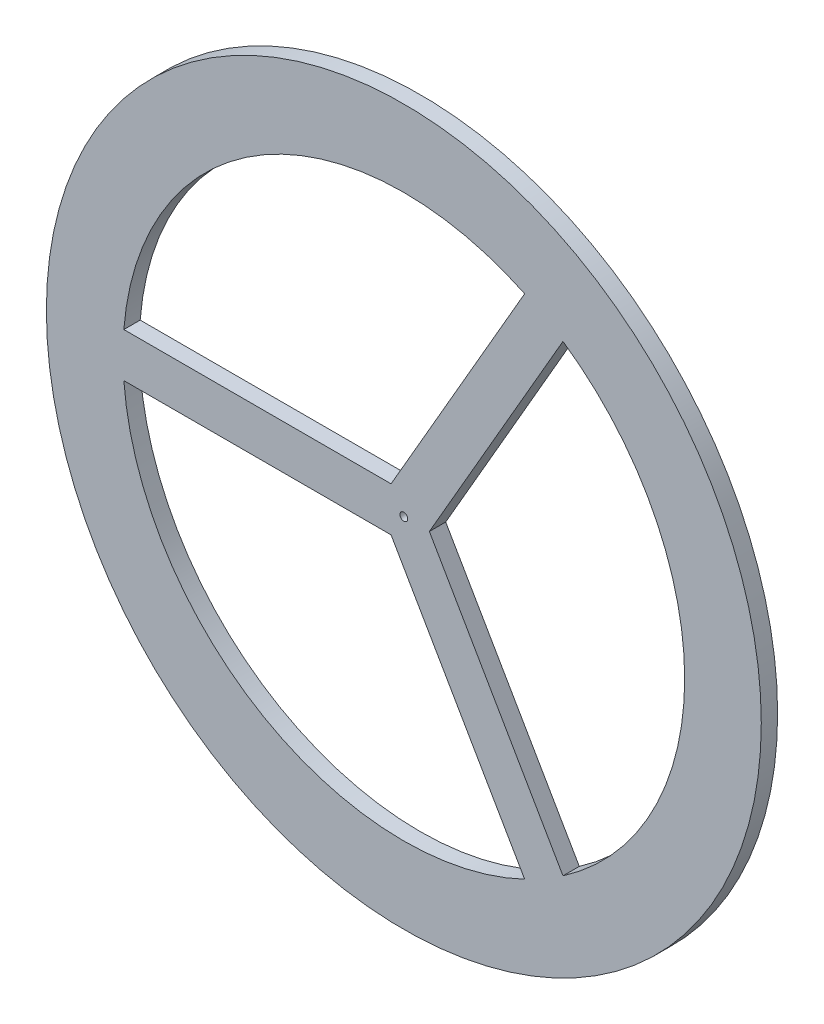
from build123d import *

# Parameters (mm, degrees)
SKETCH1_R               = 175
BOSS_EXTRUDE1_DEPTH     = 8
SKETCH2_R               = 1.9
CUT_EXTRUDE2_DEPTH      = 9
CUT_EXTRUDE2_DEPTH_BACK = 1


with BuildPart() as part:
    # Sketch1 → Boss-Extrude1 (new body)
    with BuildSketch(Plane.XY):
        Circle(SKETCH1_R)
        with BuildLine():
            Line((-6.25, 10.825317547), (-137.073201247, 10.825317547))
            ThreePointArc((-137.073201247, 10.825317547), (-68.75, 119.07849302), (59.161600623, 124.121533231))
            Line((59.161600623, 124.121533231), (-6.25, 10.825317547))
        make_face(mode=Mode.SUBTRACT)
        with BuildLine():
            Line((-6.25, -10.825317547), (-137.073201247, -10.825317547))
            ThreePointArc((-137.073201247, -10.825317547), (-68.75, -119.07849302), (59.161600623, -124.121533231))
            Line((59.161600623, -124.121533231), (-6.25, -10.825317547))
        make_face(mode=Mode.SUBTRACT)
        with BuildLine():
            Line((12.5, 0), (77.911600623, 113.296215684))
            ThreePointArc((77.911600623, 113.296215684), (137.5, 0), (77.911600623, -113.296215684))
            Line((77.911600623, -113.296215684), (12.5, 0))
        make_face(mode=Mode.SUBTRACT)
    extrude(amount=BOSS_EXTRUDE1_DEPTH)

    # Sketch2 → Cut-Extrude2 (cut, two sides)
    with BuildSketch(Plane.XY) as cut_extrude2_sk:
        Circle(SKETCH2_R)
    extrude(amount=CUT_EXTRUDE2_DEPTH, mode=Mode.SUBTRACT)
    extrude(cut_extrude2_sk.sketch, amount=-CUT_EXTRUDE2_DEPTH_BACK, mode=Mode.SUBTRACT)


solid = part.part
